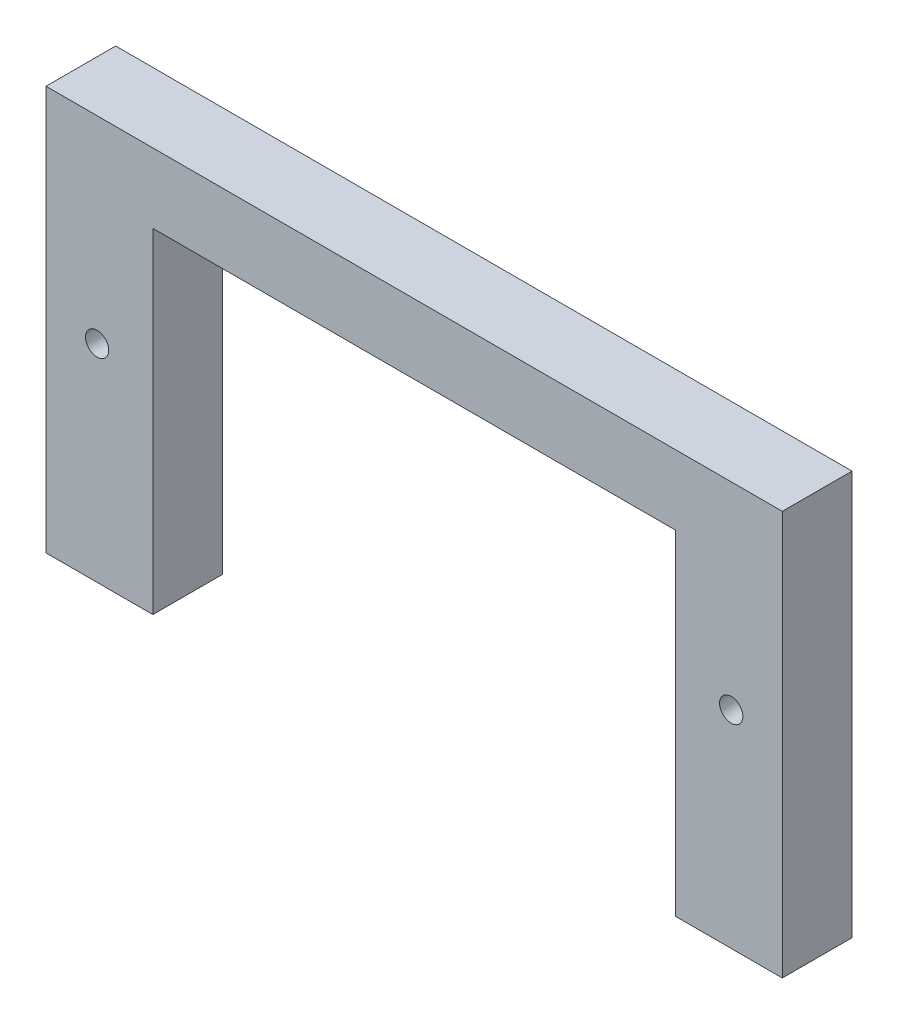
from build123d import *

# Parameters (mm, degrees)
SKETCH1_R           = 0.5
BOSS_EXTRUDE1_DEPTH = 3


with BuildPart() as part:
    # Sketch1 → Boss-Extrude1 (new body)
    with BuildSketch(Plane.XY):
        Polygon((0, 0), (4.6, 0), (4.6, 14.4), (27.1, 14.4), (27.1, 0), (31.7, 0), (31.7, 17.4), (0, 17.4), align=None)
        with Locations((29.5, 8.9)):
            Circle(SKETCH1_R, mode=Mode.SUBTRACT)
        with Locations((2.2, 8.9)):
            Circle(SKETCH1_R, mode=Mode.SUBTRACT)
    extrude(amount=BOSS_EXTRUDE1_DEPTH)


solid = part.part
